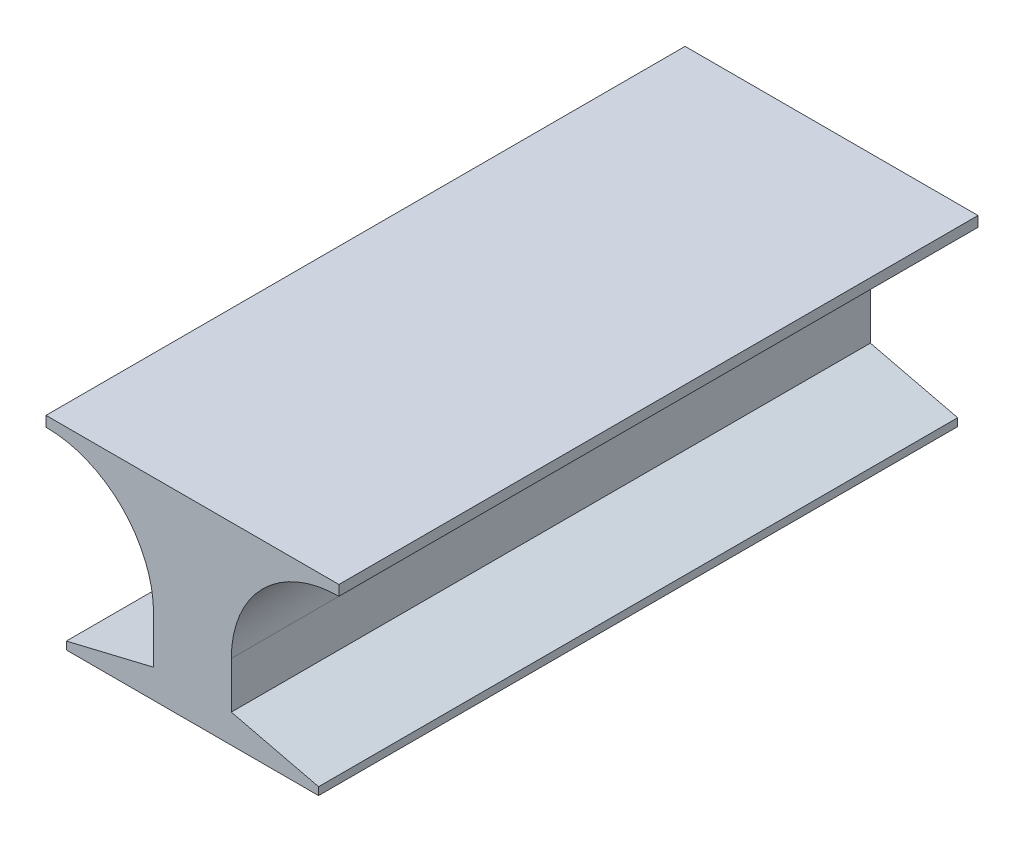
from build123d import *

# Parameters (mm, degrees)
SKETCH2_W           = 1117.6
SKETCH2_H           = 2438.4
BOSS_EXTRUDE1_DEPTH = 736.6
CUT_EXTRUDE1_DEPTH  = 2439.4


with BuildPart() as part:
    # Sketch2 → Boss-Extrude1 (new body)
    with BuildSketch(Plane(origin=(0, 0, 0), x_dir=(1, 0, 0), z_dir=(0, 1, 0))):
        Rectangle(SKETCH2_W, SKETCH2_H)
    extrude(amount=BOSS_EXTRUDE1_DEPTH)

    # Sketch3 → Cut-Extrude1 (cut, through all)
    with BuildSketch(Plane.XY.offset(1219.2)):
        with BuildLine():
            Line((-148.287166209, 109.524357008), (-148.287166209, 286.88743816))
            ThreePointArc((-148.287166209, 286.88743816), (-268.523591462, 577.163846698), (-558.8, 697.400271951))
            Line((-558.8, 697.400271951), (-558.8, 0))
            Line((-558.8, 0), (-481.206392305, 0))
            Line((-481.206392305, 0), (-481.206392305, 29.565590915))
            Line((-481.206392305, 29.565590915), (-148.287166209, 109.524357008))
        make_face()
        with BuildLine():
            Line((558.8, 0), (481.206392305, 0))
            Line((481.206392305, 0), (481.206392305, 29.565590915))
            Line((481.206392305, 29.565590915), (148.287166209, 109.524357008))
            Line((148.287166209, 109.524357008), (148.287166209, 286.88743816))
            ThreePointArc((148.287166209, 286.88743816), (268.523591462, 577.163846698), (558.8, 697.400271951))
            Line((558.8, 697.400271951), (558.8, 0))
        make_face()
    extrude(amount=-CUT_EXTRUDE1_DEPTH, mode=Mode.SUBTRACT)


solid = part.part
